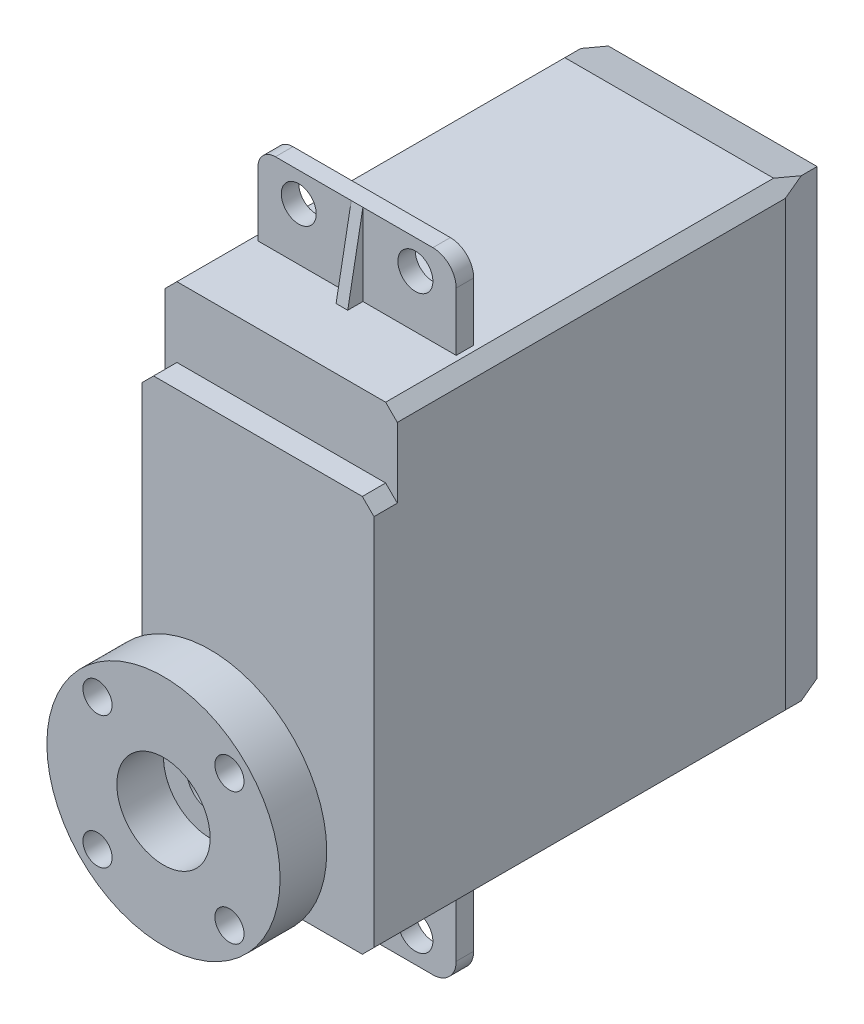
from build123d import *
from OCP.BRepFilletAPI import BRepFilletAPI_MakeFillet

# Parameters (mm, degrees)
SKETCH_1_W                  = 19.9
SKETCH_1_H                  = 40
EXTRUDE_1_DEPTH             = 39
CHAMFER_1_SIZE              = 1
CHAMFER_1_SIZE2             = 3.732050808
SKETCH_2_W                  = 19.9
SKETCH_2_H                  = 6
CUT_EXTRUDE_1_DEPTH         = 2
SKETCH_4_W                  = 17
SKETCH_4_H                  = 7
SKETCH_4_R                  = 1.5
EXTRUDE_2_DEPTH             = 1.5
RIB_1_REACH                 = 50.467
SKETCH_5_WALL_W             = 106.052709114
SKETCH_5_WALL_H             = 1
FILLET_1_R1                 = 2
FILLET_1_R2                 = 1.5
FILLET_1_OF_MIRROR_1_R1     = 2
FILLET_1_OF_MIRROR_1_R2     = 1.5
SKETCH_7_W                  = 4.1
SKETCH_7_H                  = 4
MM_1_D                      = 4
MM_1_DEPTH                  = 10
MM_1_TIP                    = 1.201721238
CHAMFER_2_SIZE              = 1
EXTRUDE_START               = 4
SKETCH_13_R                 = 10
SKETCH_13_R_2               = 4
EXTRUDE_3_DEPTH             = 4
SKETCH_15_W                 = 1.25
SKETCH_15_H                 = 4.001
HOLE_WIZARD_M3_1_AT_2_COUNT = 2
HOLE_WIZARD_M3_1_AT_2_PITCH = 11.313708499
HOLE_WIZARD_M3_1_AT_3_COUNT = 2
HOLE_WIZARD_M3_1_AT_3_PITCH = 16
HOLE_WIZARD_M3_1_AT_4_COUNT = 2
HOLE_WIZARD_M3_1_AT_4_PITCH = 11.313708499


with BuildPart() as part:
    # 草图1 → 凸台-拉伸1 (new body)
    with BuildSketch(Plane.XY):
        Rectangle(SKETCH_1_W, SKETCH_1_H)
    extrude(amount=EXTRUDE_1_DEPTH)

    # 倒角1
    chamfer_1_edges = [part.edges().sort_by_distance(p)[0] for p in [
        (9.95, 0, 0),
        (0, -20, 0),
        (-9.95, 0, 0),
        (0, 20, 0),
    ]]
    chamfer_1_side = [part.faces().sort_by_distance(p)[0] for p in [
        (0, 0, 0),
    ]]
    chamfer(chamfer_1_edges, length=CHAMFER_1_SIZE, length2=CHAMFER_1_SIZE2, reference=chamfer_1_side[0])

    # 草图2 → 切除-拉伸1 (cut)
    with BuildSketch(Plane.XY.offset(39)):
        with Locations((0, 17)):
            Rectangle(SKETCH_2_W, SKETCH_2_H)
    extrude(amount=-CUT_EXTRUDE_1_DEPTH, mode=Mode.SUBTRACT)

    # 草图4 → 凸台-拉伸2 (add)
    with BuildSketch(Plane.XY.offset(29)):
        with Locations((0, 23.5)):
            Rectangle(SKETCH_4_W, SKETCH_4_H)
        with Locations((-5, 24.5)):
            Circle(SKETCH_4_R, mode=Mode.SUBTRACT)
        with Locations((5, 24.5)):
            Circle(SKETCH_4_R, mode=Mode.SUBTRACT)
    extrude_2 = extrude(amount=EXTRUDE_2_DEPTH)

    # 草图5 wall → 筋1 (add, up to next)
    with BuildSketch(Plane(origin=(0, 23.5, 31.15), x_dir=(0, -0.983188736076, 0.182592193843), z_dir=(0, -0.182592193843, -0.983188736076)), mode=Mode.PRIVATE) as rib_1_sk1:
        Rectangle(SKETCH_5_WALL_W, SKETCH_5_WALL_H)
    rib_1_tool1 = extrude(rib_1_sk1.sketch, amount=RIB_1_REACH, mode=Mode.PRIVATE) - part.part
    rib_1 = rib_1_tool1.solids().sort_by_distance((0, 23.5, 31.15))[0]
    add(rib_1)

    # 圆角1: one fillet with a radius per group of edges: ONE call of the kernel's fillet builder (fillet() takes one radius for all edges)
    fillet_1_edges_1 = [part.edges().sort_by_distance(p)[0] for p in [
        (8.5, 27, 29.75),
    ]]
    fillet_1_edges_2 = [part.edges().sort_by_distance(p)[0] for p in [
        (-8.5, 27, 29.75),
    ]]
    fillet_1 = BRepFilletAPI_MakeFillet(part.part.solid().wrapped)
    for e in fillet_1_edges_1:
        fillet_1.Add(FILLET_1_R1, e.wrapped)
    for e in fillet_1_edges_2:
        fillet_1.Add(FILLET_1_R2, e.wrapped)
    add(Compound.cast(fillet_1.Shape()), mode=Mode.REPLACE)

    # 镜向1: 凸台-拉伸2, 筋1 across plane
    add(extrude_2.mirror(Plane.ZX))
    add(rib_1.mirror(Plane.ZX))

    # 圆角1 of 镜向1: one fillet with a radius per group of edges: ONE call of the kernel's fillet builder (fillet() takes one radius for all edges)
    fillet_1_of_mirror_1_edges_1 = [part.edges().sort_by_distance(p)[0] for p in [
        (8.5, -27, 29.75),
    ]]
    fillet_1_of_mirror_1_edges_2 = [part.edges().sort_by_distance(p)[0] for p in [
        (-8.5, -27, 29.75),
    ]]
    fillet_1_of_mirror_1 = BRepFilletAPI_MakeFillet(part.part.solid().wrapped)
    for e in fillet_1_of_mirror_1_edges_1:
        fillet_1_of_mirror_1.Add(FILLET_1_OF_MIRROR_1_R1, e.wrapped)
    for e in fillet_1_of_mirror_1_edges_2:
        fillet_1_of_mirror_1.Add(FILLET_1_OF_MIRROR_1_R2, e.wrapped)
    add(Compound.cast(fillet_1_of_mirror_1.Shape()), mode=Mode.REPLACE)

    # 草图7 → 旋转2 (revolve)
    with BuildSketch(Plane(origin=(0, 0, 0), x_dir=(0, 0, -1), z_dir=(1, 0, 0))):
        with Locations((-41.05, -7.8)):
            Rectangle(SKETCH_7_W, SKETCH_7_H)
    revolve(axis=Axis((0, -9.8, 39), (0, 0, 1)))

    # 大小mm 暗销孔1
    with Locations(Plane(origin=(0, -9.8, 43.1), x_dir=(0, 1, 0), z_dir=(0, 0, 1))):
        with Locations((0, 0)):
            Hole(MM_1_D / 2, depth=MM_1_DEPTH)
            with Locations((0, 0, -(MM_1_DEPTH + MM_1_TIP / 2))):  # 118° drill point
                Cone(0, MM_1_D / 2, MM_1_TIP, mode=Mode.SUBTRACT)

    # 倒角2
    chamfer_2_edges = [part.edges().sort_by_distance(p)[0] for p in [
        (9.95, 14, 38),
        (-9.95, 14, 38),
        (9.95, -20, 21.366025404),
        (9.95, 20, 20.366025404),
        (-9.95, -20, 21.366025404),
        (-9.95, 20, 20.366025404),
    ]]
    chamfer(chamfer_2_edges, length=CHAMFER_2_SIZE)


with BuildPart() as body_2:
    # 草图13 → 凸台-拉伸3 (new body)
    with BuildSketch(Plane.XY.offset(43.1).offset(EXTRUDE_START)):
        with Locations((0, -9.8)):
            Circle(SKETCH_13_R)
        with Locations((0, -9.8)):
            Circle(SKETCH_13_R_2, mode=Mode.SUBTRACT)
    extrude(amount=-EXTRUDE_3_DEPTH)

    # 草图15 → M3 螺纹孔的螺纹孔钻头1 (revolve, cut)
    with BuildSketch(Plane(origin=(5.656854249, -4.143145751, 43.1), x_dir=(0, 1, 0), z_dir=(1, 0, 0))):
        with Locations((0.625, 2.0005)):
            Rectangle(SKETCH_15_W, SKETCH_15_H)
    hole_wizard_m3_1 = revolve(axis=Axis((5.656854249, -4.143145751, 36.75), (0, 0, 1)), mode=Mode.SUBTRACT)

    # M3 螺纹孔的螺纹孔钻头1 at 2: M3 螺纹孔的螺纹孔钻头1 ×2
    with Locations(*[(0, -i * HOLE_WIZARD_M3_1_AT_2_PITCH, 0) for i in range(1, HOLE_WIZARD_M3_1_AT_2_COUNT)]):
        add(hole_wizard_m3_1, mode=Mode.SUBTRACT)

    # M3 螺纹孔的螺纹孔钻头1 at 3: M3 螺纹孔的螺纹孔钻头1 ×2
    with Locations(*[Vector(-0.7071067811865476, -0.7071067811865476, 0) * (i * HOLE_WIZARD_M3_1_AT_3_PITCH) for i in range(1, HOLE_WIZARD_M3_1_AT_3_COUNT)]):
        add(hole_wizard_m3_1, mode=Mode.SUBTRACT)

    # M3 螺纹孔的螺纹孔钻头1 at 4: M3 螺纹孔的螺纹孔钻头1 ×2
    with Locations(*[(-i * HOLE_WIZARD_M3_1_AT_4_PITCH, 0, 0) for i in range(1, HOLE_WIZARD_M3_1_AT_4_COUNT)]):
        add(hole_wizard_m3_1, mode=Mode.SUBTRACT)


solid = Compound([part.part, body_2.part])
